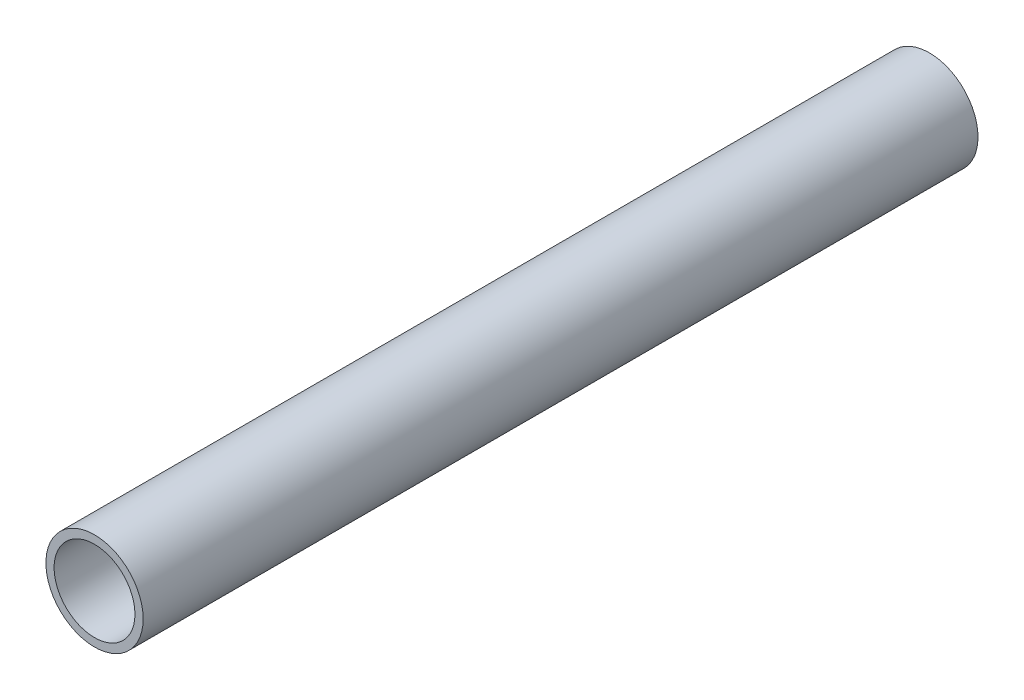
from build123d import *

# Parameters (mm, degrees)
SKETCH1_R           = 21.082
SKETCH1_R_2         = 17.526
BOSS_EXTRUDE1_DEPTH = 361.95


with BuildPart() as part:
    # Sketch1 → Boss-Extrude1 (new body)
    with BuildSketch(Plane.XY):
        Circle(SKETCH1_R)
        Circle(SKETCH1_R_2, mode=Mode.SUBTRACT)
    extrude(amount=BOSS_EXTRUDE1_DEPTH)


solid = part.part
